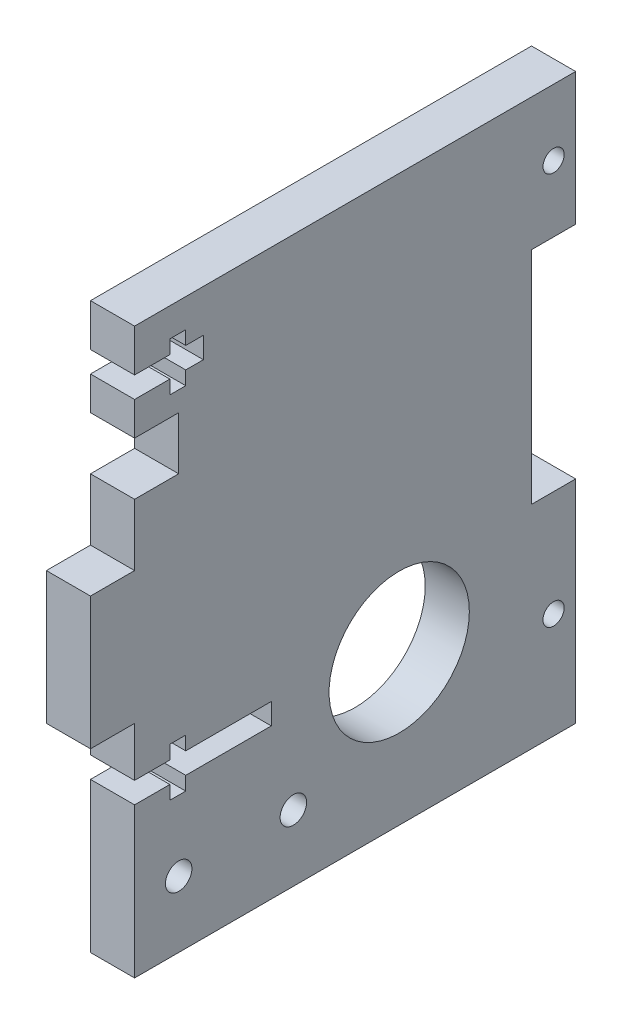
from build123d import *

# Parameters (mm, degrees)
SKETCH1_R           = 7.95
SKETCH1_R_2         = 1.5
SKETCH1_R_3         = 1.2
SKETCH1_W           = 8
SKETCH1_H           = 2.4
BOSS_EXTRUDE1_DEPTH = 5
CUT_EXTRUDE1_DEPTH  = 6


with BuildPart() as part:
    # Sketch1 → Boss-Extrude1 (new body)
    with BuildSketch(Plane(origin=(0, 0, 0), x_dir=(0, 0, -1), z_dir=(1, 0, 0))):
        Polygon((-50, 0), (0, 0), (0, 24), (-5, 24), (-5, 49), (0, 49), (0, 64), (-50, 64), (-50, 53), (-45, 53), (-45, 47), (-50, 47), (-50, 40), (-55, 40), (-55, 25), (-50, 25), align=None)
        with Locations((-20, 17)):
            Circle(SKETCH1_R, mode=Mode.SUBTRACT)
        with Locations((-45, 7.5)):
            Circle(SKETCH1_R_2, mode=Mode.SUBTRACT)
        with Locations((-32, 7.5)):
            Circle(SKETCH1_R_2, mode=Mode.SUBTRACT)
        with Locations((-2.5, 56.5)):
            Circle(SKETCH1_R_3, mode=Mode.SUBTRACT)
        with Locations((-2.5, 12)):
            Circle(SKETCH1_R_3, mode=Mode.SUBTRACT)
        with Locations((-38.5, 18.2)):
            Rectangle(SKETCH1_W, SKETCH1_H, mode=Mode.SUBTRACT)
    extrude(amount=BOSS_EXTRUDE1_DEPTH)

    # Sketch2 → Cut-Extrude1 (cut, through all)
    with BuildSketch(Plane(origin=(5, 0, 0), x_dir=(0, 0, -1), z_dir=(1, 0, 0))):
        Polygon((-50, 56.8), (-46, 56.8), (-46, 55.25), (-44.2, 55.25), (-44.2, 56.8), (-42.2, 56.8), (-42.2, 59.2), (-44.2, 59.2), (-44.2, 60.75), (-46, 60.75), (-46, 59.2), (-50, 59.2), align=None)
        Polygon((-44.2, 19.4), (-42.2, 19.4), (-42.2, 17), (-44.2, 17), (-44.2, 15.45), (-46, 15.45), (-46, 17), (-50, 17), (-50, 19.4), (-46, 19.4), (-46, 20.95), (-44.2, 20.95), align=None)
    extrude(amount=-CUT_EXTRUDE1_DEPTH, mode=Mode.SUBTRACT)


solid = part.part
